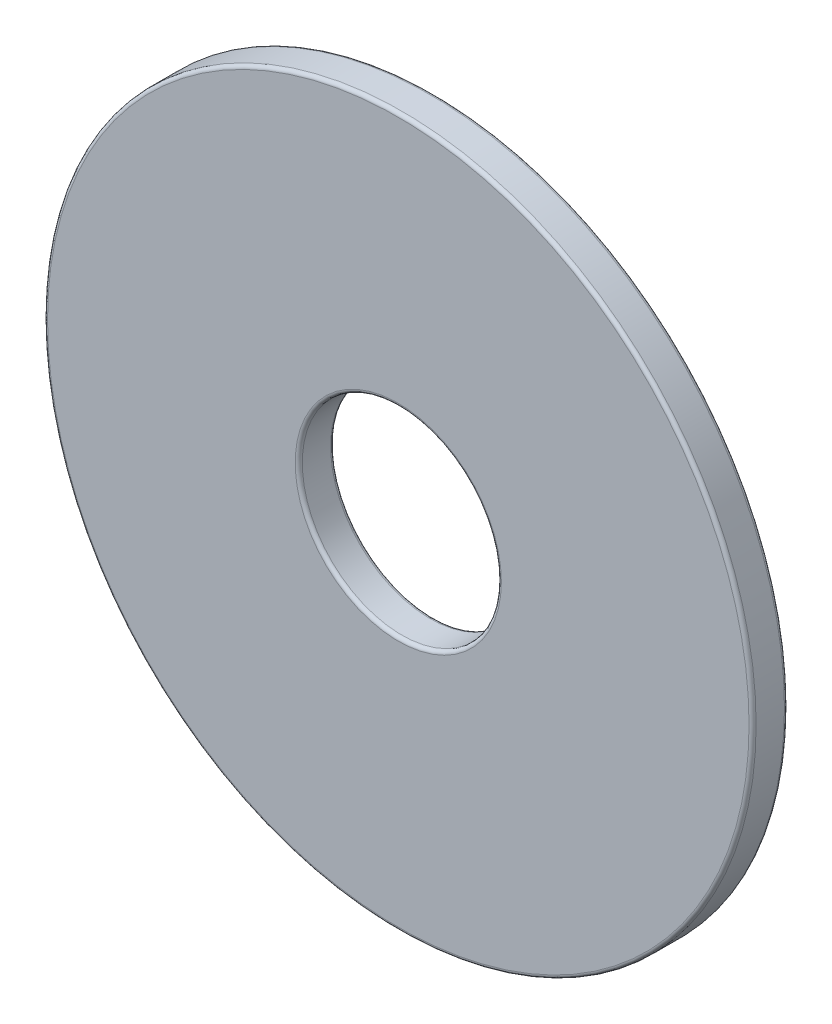
from build123d import *

# Parameters (mm, degrees)
BOSS_EXTRUDE1_START = 0.635
SKETCH3_R           = 12.7
SKETCH3_R_2         = 3.5687
BOSS_EXTRUDE1_DEPTH = 1.27
FILLET1_R           = 0.127


with BuildPart() as part:
    # Sketch3 → Boss-Extrude1 (new body)
    with BuildSketch(Plane.XY.offset(BOSS_EXTRUDE1_START)):
        Circle(SKETCH3_R)
        Circle(SKETCH3_R_2, mode=Mode.SUBTRACT)
    extrude(amount=-BOSS_EXTRUDE1_DEPTH)

    # Fillet1
    fillet1_edges = [part.edges().sort_by_distance(p)[0] for p in [
        (-12.7, 0, 0.635),
        (-12.7, 0, -0.635),
        (-3.5687, 0, -0.635),
        (-3.5687, 0, 0.635),
    ]]
    fillet(fillet1_edges, radius=FILLET1_R)


solid = part.part
